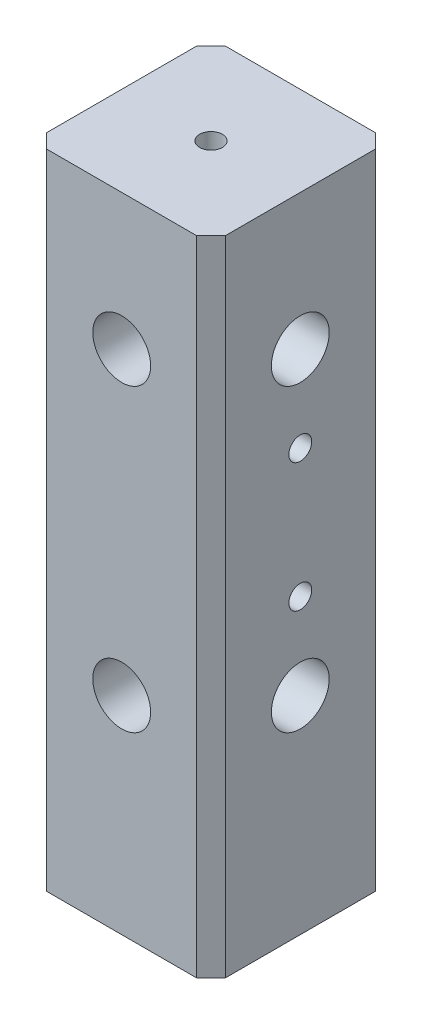
from build123d import *

# Parameters (mm, degrees)
SKETCH1_W           = 25
SKETCH1_H           = 25
BOSS_EXTRUDE1_DEPTH = 90
SKETCH2_R           = 4.05
CUT_EXTRUDE1_DEPTH  = 8
SKETCH3_R           = 4.05
CUT_EXTRUDE7_DEPTH  = 8
CHAMFER1_SIZE       = 2
SKETCH5_R           = 1.6
CUT_EXTRUDE8_DEPTH  = 12.5
SKETCH7_R           = 1.6
CUT_EXTRUDE9_DEPTH  = 10


with BuildPart() as part:
    # Sketch1 → Boss-Extrude1 (new body)
    with BuildSketch(Plane(origin=(0, 0, 0), x_dir=(1, 0, 0), z_dir=(0, 1, 0))):
        Rectangle(SKETCH1_W, SKETCH1_H)
    extrude(amount=BOSS_EXTRUDE1_DEPTH)

    # Sketch2 → Cut-Extrude1 (cut)
    with BuildSketch(Plane(origin=(12.5, 0, 0), x_dir=(0, 0, -1), z_dir=(1, 0, 0))):
        with Locations((0, 71)):
            Circle(SKETCH2_R)
        with Locations((0, 29)):
            Circle(SKETCH2_R)
    extrude(amount=-CUT_EXTRUDE1_DEPTH, mode=Mode.SUBTRACT)

    # Sketch3 → Cut-Extrude7 (cut)
    with BuildSketch(Plane.XY.offset(12.5)):
        with Locations((0, 29)):
            Circle(SKETCH3_R)
        with Locations((0, 71)):
            Circle(SKETCH3_R)
    extrude(amount=-CUT_EXTRUDE7_DEPTH, mode=Mode.SUBTRACT)

    # Chamfer1
    chamfer1_edges = [part.edges().sort_by_distance(p)[0] for p in [
        (12.5, 45, 12.5),
        (-12.5, 45, 12.5),
        (-12.5, 45, -12.5),
        (12.5, 45, -12.5),
    ]]
    chamfer(chamfer1_edges, length=CHAMFER1_SIZE)

    # Sketch5 → Cut-Extrude8 (cut)
    with BuildSketch(Plane(origin=(12.5, 0, 0), x_dir=(0, 0, -1), z_dir=(1, 0, 0))):
        with Locations((0, 59)):
            Circle(SKETCH5_R)
        with Locations((0, 41)):
            Circle(SKETCH5_R)
    extrude(amount=-CUT_EXTRUDE8_DEPTH, mode=Mode.SUBTRACT)

    # Sketch7 → Cut-Extrude9 (cut)
    with BuildSketch(Plane(origin=(0, 90, 0), x_dir=(1, 0, 0), z_dir=(0, 1, 0))):
        Circle(SKETCH7_R)
    extrude(amount=-CUT_EXTRUDE9_DEPTH, mode=Mode.SUBTRACT)


solid = part.part
